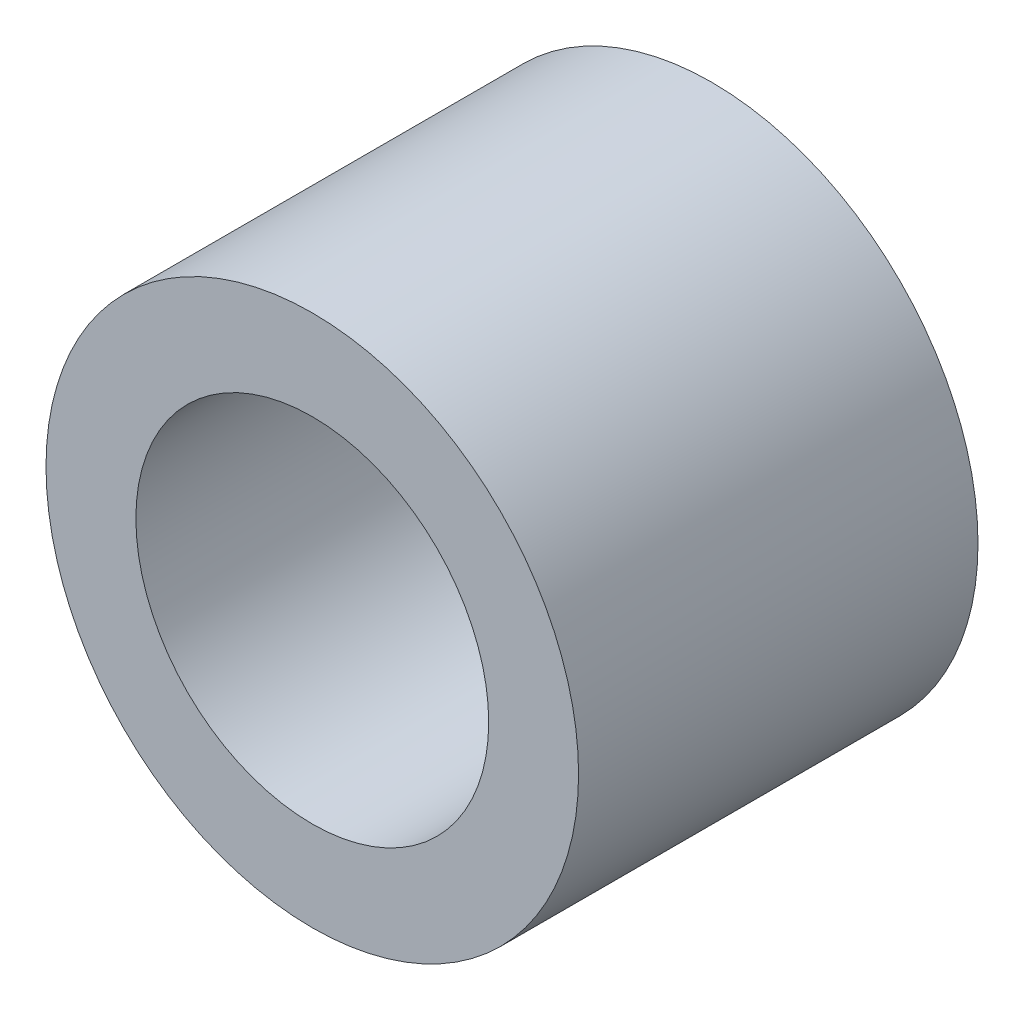
from build123d import *

# Parameters (mm, degrees)
SKETCH1_R           = 4
SKETCH1_R_2         = 2.65
EXTRUDE1_DEPTH      = 3
EXTRUDE1_DEPTH_BACK = 3


with BuildPart() as part:
    # Sketch1 → Extrude1 (new body, two sides)
    with BuildSketch(Plane.XY) as extrude1_sk:
        Circle(SKETCH1_R)
        Circle(SKETCH1_R_2, mode=Mode.SUBTRACT)
    extrude(amount=EXTRUDE1_DEPTH)
    extrude(extrude1_sk.sketch, amount=-EXTRUDE1_DEPTH_BACK)


solid = part.part
